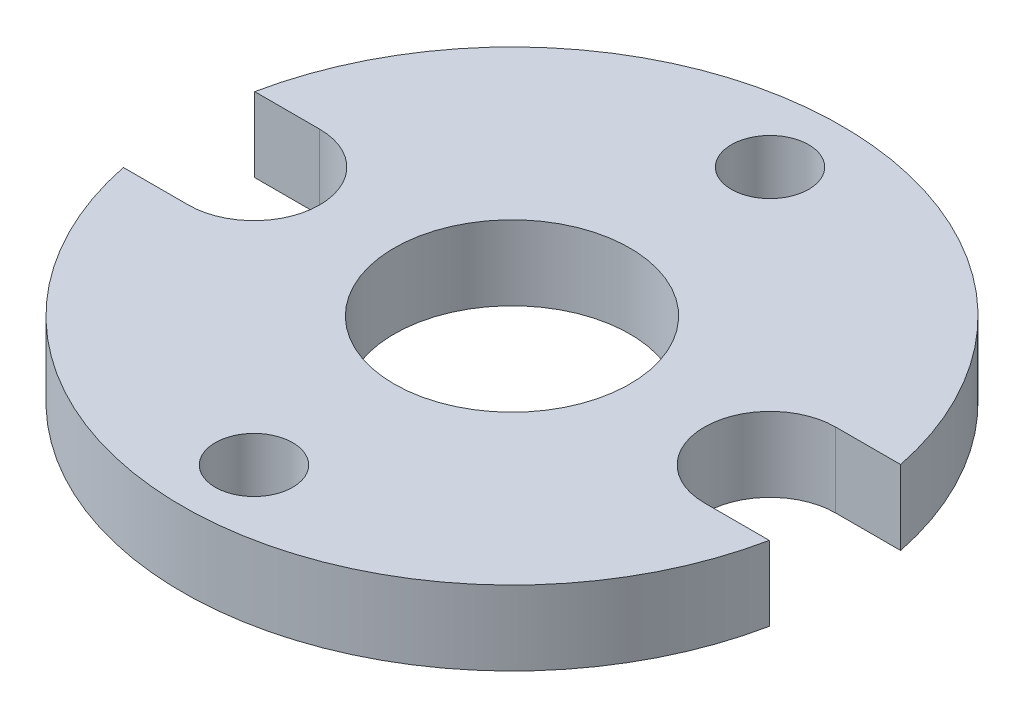
from build123d import *

# Parameters (mm, degrees)
SKETCH1_R           = 5.025
SKETCH1_R_2         = 1.65
BOSS_EXTRUDE1_DEPTH = 3.175


with BuildPart() as part:
    # Sketch1 → Boss-Extrude1 (new body)
    with BuildSketch(Plane(origin=(0, 0, 0), x_dir=(1, 0, 0), z_dir=(0, 1, 0))):
        with BuildLine():
            Line((-11, 2.8), (-13.768169813, 2.8))
            ThreePointArc((-13.768169813, 2.8), (0, 14.05), (13.768169813, 2.8))
            Line((13.768169813, 2.8), (11, 2.8))
            ThreePointArc((11, 2.8), (8.2, 0), (11, -2.8))
            Line((11, -2.8), (13.768169813, -2.8))
            ThreePointArc((13.768169813, -2.8), (0, -14.05), (-13.768169813, -2.8))
            Line((-13.768169813, -2.8), (-11, -2.8))
            ThreePointArc((-11, -2.8), (-8.2, 0), (-11, 2.8))
        make_face()
        Circle(SKETCH1_R, mode=Mode.SUBTRACT)
        with Locations((0, 11)):
            Circle(SKETCH1_R_2, mode=Mode.SUBTRACT)
        with Locations((0, -11)):
            Circle(SKETCH1_R_2, mode=Mode.SUBTRACT)
    extrude(amount=BOSS_EXTRUDE1_DEPTH)


solid = part.part
